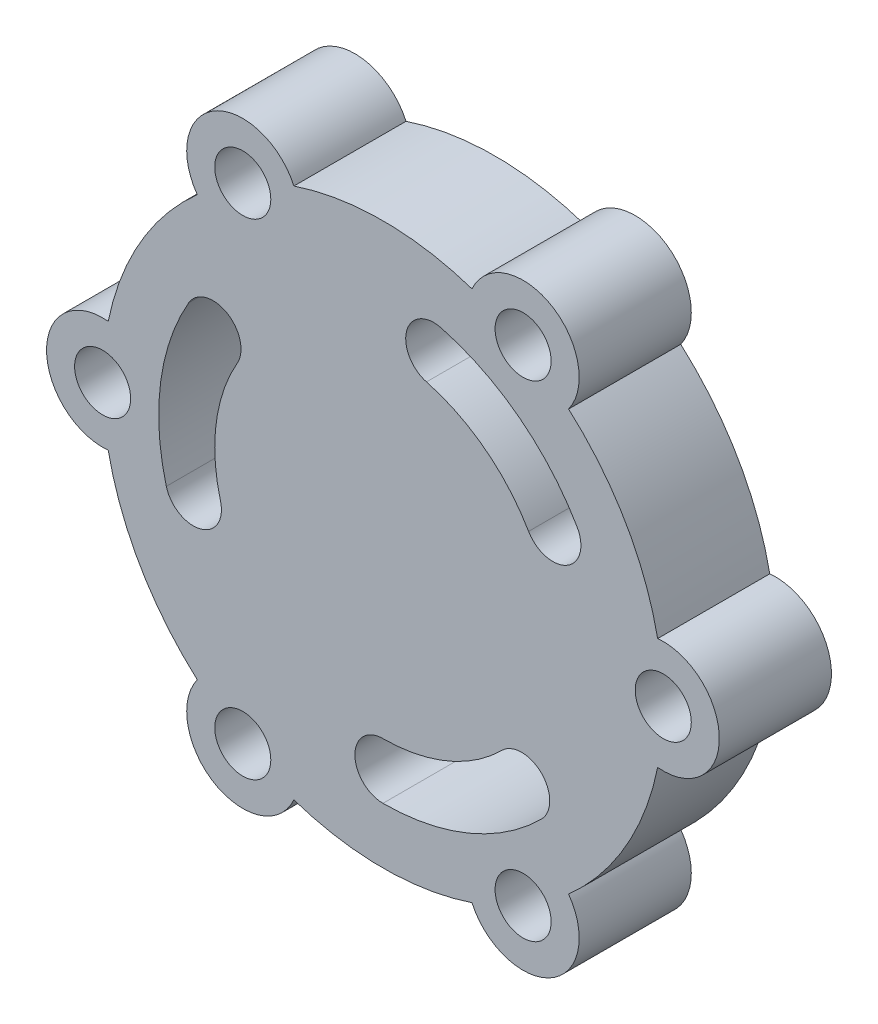
from build123d import *

# Parameters (mm, degrees)
SKETCH2_R           = 5
BOSS_EXTRUDE2_DEPTH = 20


with BuildPart() as part:
    # Sketch2 → Boss-Extrude2 (new body)
    with BuildSketch(Plane.XY):
        with BuildLine():
            ThreePointArc((-49, -9.949874371), (-43.301270189, -25), (-33.11684397, -37.4603076))
            ThreePointArc((-33.11684397, -37.4603076), (-30, -51.961524227), (-15.88315603, -47.410181971))
            ThreePointArc((-15.88315603, -47.410181971), (0, -50), (15.88315603, -47.410181971))
            ThreePointArc((15.88315603, -47.410181971), (30, -51.961524227), (33.11684397, -37.4603076))
            ThreePointArc((33.11684397, -37.4603076), (43.301270189, -25), (49, -9.949874371))
            ThreePointArc((49, -9.949874371), (60, 0), (49, 9.949874371))
            ThreePointArc((49, 9.949874371), (43.301270189, 25), (33.11684397, 37.4603076))
            ThreePointArc((33.11684397, 37.4603076), (30, 51.961524227), (15.88315603, 47.410181971))
            ThreePointArc((15.88315603, 47.410181971), (0, 50), (-15.88315603, 47.410181971))
            ThreePointArc((-15.88315603, 47.410181971), (-30, 51.961524227), (-33.11684397, 37.4603076))
            ThreePointArc((-33.11684397, 37.4603076), (-43.301270189, 25), (-49, 9.949874371))
            ThreePointArc((-49, 9.949874371), (-60, 0), (-49, -9.949874371))
        make_face()
        with Locations((-50, 0)):
            Circle(SKETCH2_R, mode=Mode.SUBTRACT)
        with Locations((-25, 43.301270189)):
            Circle(SKETCH2_R, mode=Mode.SUBTRACT)
        with Locations((25, 43.301270189)):
            Circle(SKETCH2_R, mode=Mode.SUBTRACT)
        with Locations((50, 0)):
            Circle(SKETCH2_R, mode=Mode.SUBTRACT)
        with Locations((25, -43.301270189)):
            Circle(SKETCH2_R, mode=Mode.SUBTRACT)
        with Locations((-25, -43.301270189)):
            Circle(SKETCH2_R, mode=Mode.SUBTRACT)
        with BuildLine():
            ThreePointArc((34.641016151, 20), (24.35045716, 31.734133612), (10.352761804, 38.637033052))
            ThreePointArc((10.352761804, 38.637033052), (4.229037447, 35.101499146), (7.764571353, 28.977774789))
            ThreePointArc((7.764571353, 28.977774789), (18.26284287, 23.800600209), (25.980762114, 15))
            ThreePointArc((25.980762114, 15), (32.810889132, 13.169872981), (34.641016151, 20))
        make_face(mode=Mode.SUBTRACT)
        with BuildLine():
            ThreePointArc((0, -40), (15.307337295, -36.9551813), (28.284271247, -28.284271247))
            ThreePointArc((28.284271247, -28.284271247), (28.284271247, -21.213203436), (21.213203436, -21.213203436))
            ThreePointArc((21.213203436, -21.213203436), (11.480502971, -27.716385975), (0, -30))
            ThreePointArc((0, -30), (-5, -35), (0, -40))
        make_face(mode=Mode.SUBTRACT)
        with BuildLine():
            ThreePointArc((-34.641016151, 20), (-39.657794455, 5.221047689), (-38.637033052, -10.352761804))
            ThreePointArc((-38.637033052, -10.352761804), (-32.513308695, -13.88829571), (-28.977774789, -7.764571353))
            ThreePointArc((-28.977774789, -7.764571353), (-29.743345841, 3.915785767), (-25.980762114, 15))
            ThreePointArc((-25.980762114, 15), (-27.810889132, 21.830127019), (-34.641016151, 20))
        make_face(mode=Mode.SUBTRACT)
    extrude(amount=BOSS_EXTRUDE2_DEPTH)


solid = part.part
